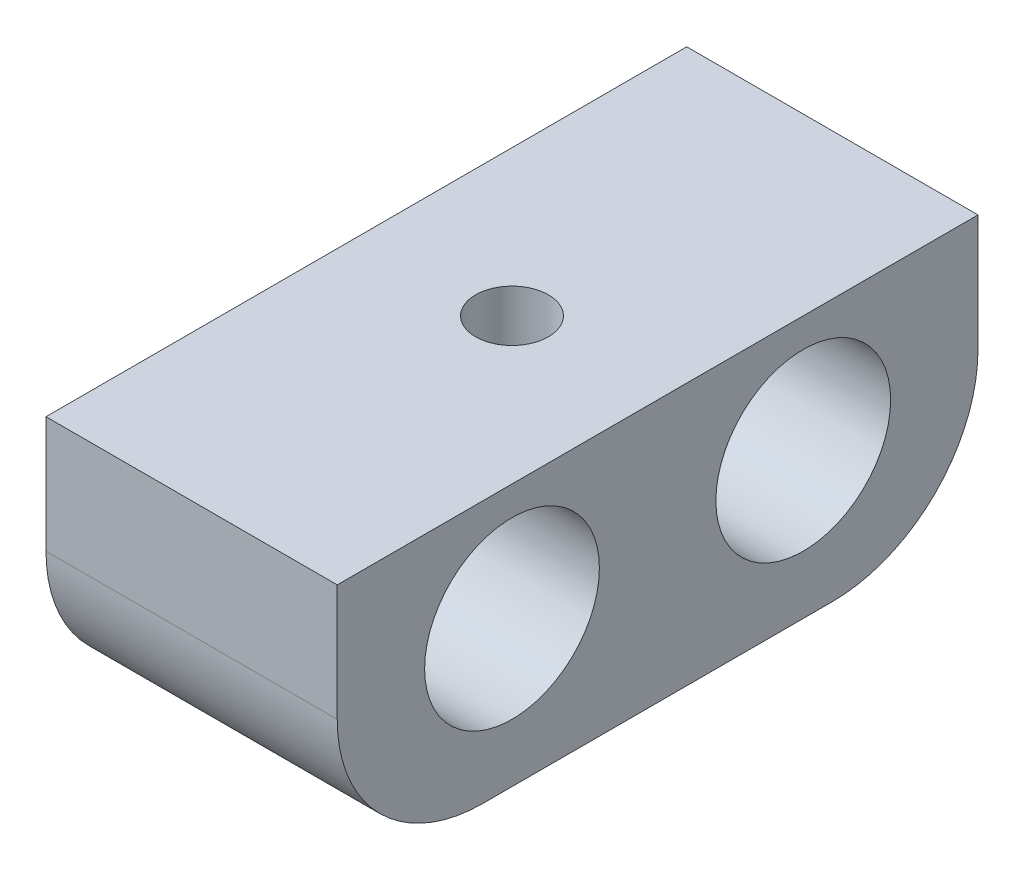
from build123d import *

# Parameters (mm, degrees)
SKETCH1_W             = 22
SKETCH1_H             = 9
SKETCH1_R             = 3
BOSS_EXTRUDE1_DEPTH   = 10
FILLET1_R             = 5
M3_TAPPED_HOLE1_D     = 2.5
M3_TAPPED_HOLE1_DEPTH = 7.5
M3_TAPPED_HOLE1_TIP   = 0.751075774


with BuildPart() as part:
    # Sketch1 → Boss-Extrude1 (new body)
    with BuildSketch(Plane(origin=(0, 0, 0), x_dir=(0, 0, -1), z_dir=(1, 0, 0))):
        with Locations((5, -0.5)):
            Rectangle(SKETCH1_W, SKETCH1_H)
        Circle(SKETCH1_R, mode=Mode.SUBTRACT)
        with Locations((10, 0)):
            Circle(SKETCH1_R, mode=Mode.SUBTRACT)
    extrude(amount=BOSS_EXTRUDE1_DEPTH)

    # Fillet1
    fillet1_edges = [part.edges().sort_by_distance(p)[0] for p in [
        (5, -5, -16),
        (5, -5, 6),
    ]]
    fillet(fillet1_edges, radius=FILLET1_R)

    # M3 Tapped Hole1
    with Locations(Plane(origin=(0, 4, 0), x_dir=(1, 0, 0), z_dir=(0, 1, 0))):
        with Locations((5, 5)):
            Hole(M3_TAPPED_HOLE1_D / 2, depth=M3_TAPPED_HOLE1_DEPTH)
            with Locations((0, 0, -(M3_TAPPED_HOLE1_DEPTH + M3_TAPPED_HOLE1_TIP / 2))):  # 118° drill point
                Cone(0, M3_TAPPED_HOLE1_D / 2, M3_TAPPED_HOLE1_TIP, mode=Mode.SUBTRACT)


solid = part.part
